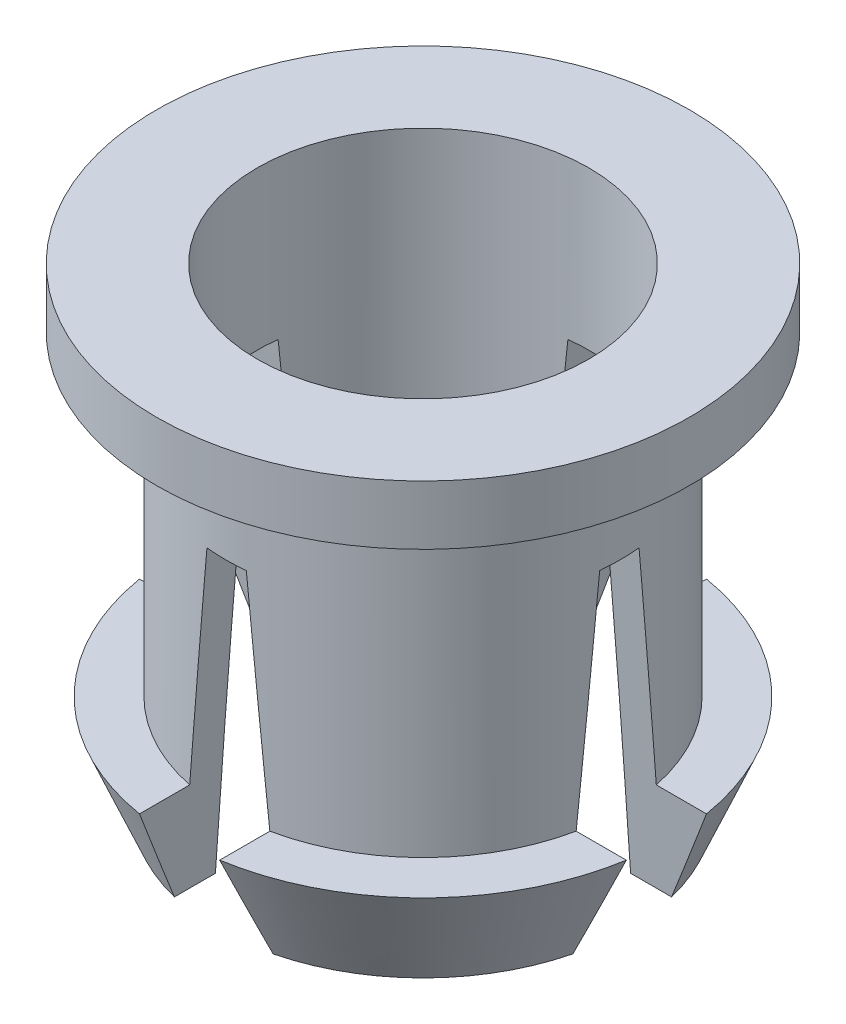
from build123d import *

# Parameters (mm, degrees)
CUT_EXTRUDE1_DEPTH = 4.375
CIRPATTERN1_COUNT  = 4


with BuildPart() as part:
    # Sketch1 → Revolve1 (revolve)
    with BuildSketch(Plane.XY):
        Polygon((2.1, 3), (2.1, -3), (2.6, -3), (3.125, -1.75), (2.5, -1.75), (2.5, 2.25), (3.375, 2.25), (3.375, 3), align=None)
    revolve(axis=Axis((0, 3, 0), (0, -1, 0)))

    # Sketch2 → Cut-Extrude1 (cut, symmetric)
    with BuildSketch(Plane.XY):
        Polygon((-0.249514725, 1), (0.249514725, 1), (0.625, -3), (-0.625, -3), align=None)
    cut_extrude1 = extrude(amount=CUT_EXTRUDE1_DEPTH, both=True, mode=Mode.SUBTRACT)

    # CirPattern1: Cut-Extrude1 ×4 about axis
    cirpattern1_axis = Axis((0, 3, 0), (0, 1, 0))
    for i in range(1, CIRPATTERN1_COUNT):
        add(cut_extrude1.rotate(cirpattern1_axis, i * 360 / CIRPATTERN1_COUNT), mode=Mode.SUBTRACT)


solid = part.part
